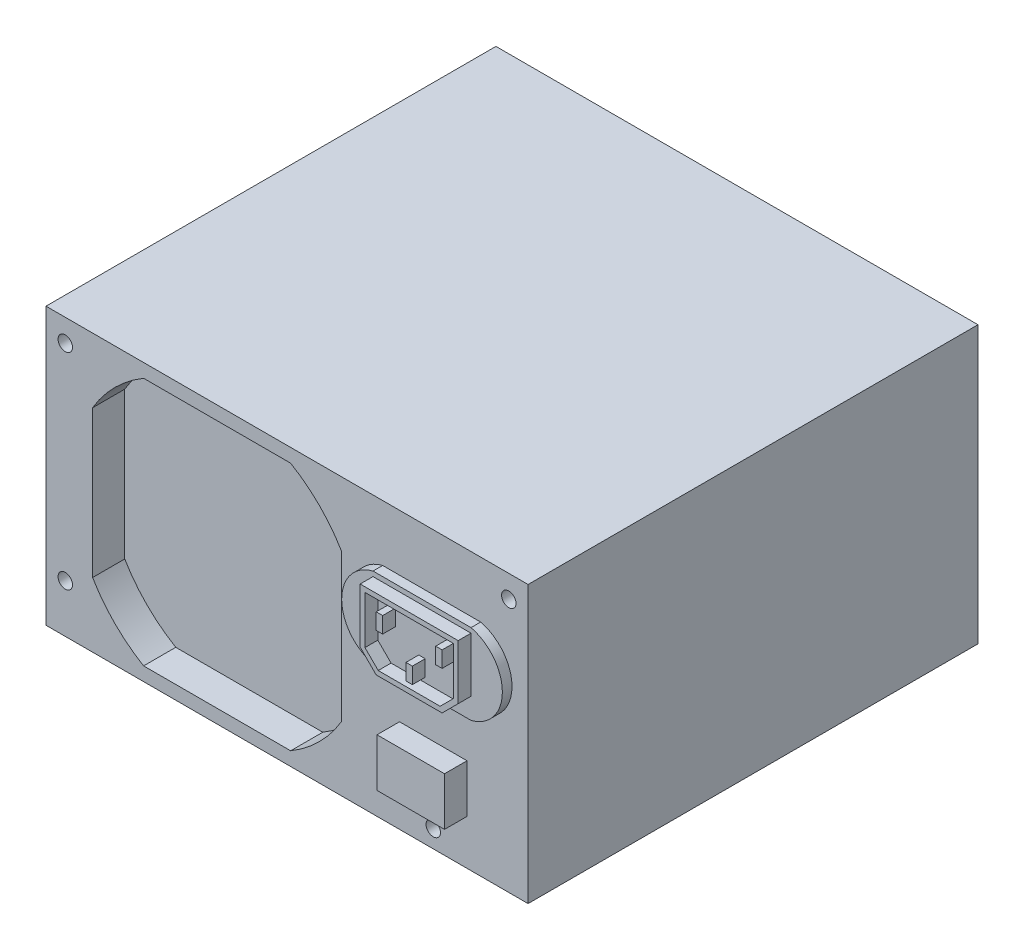
from build123d import *

# Parameters (mm, degrees)
SKETCH_1_W          = 150
SKETCH_1_H          = 86
EXTRUDE_1_DEPTH     = 140
SKETCH_4_R          = 2.25
CUT_EXTRUDE_1_DEPTH = 10
CUT_EXTRUDE_2_DEPTH = 10
EXTRUDE_2_DEPTH     = 3
SKETCH_7_W          = 2
SKETCH_7_H          = 5
EXTRUDE_3_DEPTH     = 4
SKETCH_8_W          = 21
SKETCH_8_H          = 15
EXTRUDE_4_DEPTH     = 7


with BuildPart() as part:
    # Эскиз1 → Бобышка-Вытянуть1 (new body)
    with BuildSketch(Plane.XY):
        with Locations((75, 43)):
            Rectangle(SKETCH_1_W, SKETCH_1_H)
    extrude(amount=EXTRUDE_1_DEPTH)

    # Эскиз4 → Вырез-Вытянуть1 (cut)
    with BuildSketch(Plane.XY.offset(140)):
        with Locations((6, 79)):
            Circle(SKETCH_4_R)
        with Locations((144, 79)):
            Circle(SKETCH_4_R)
        with Locations((6, 15)):
            Circle(SKETCH_4_R)
        with Locations((120.5, 5.5)):
            Circle(SKETCH_4_R)
    extrude(amount=-CUT_EXTRUDE_1_DEPTH, mode=Mode.SUBTRACT)

    # Эскиз5 → Вырез-Вытянуть2 (cut)
    with BuildSketch(Plane.XY.offset(140)):
        with BuildLine():
            Line((76.128756522, 81.75), (30.371243478, 81.75))
            ThreePointArc((30.371243478, 81.75), (21.430194847, 74.819805153), (14.5, 65.878756522))
            Line((14.5, 65.878756522), (14.5, 20.121243478))
            ThreePointArc((14.5, 20.121243478), (21.430194847, 11.180194847), (30.371243478, 4.25))
            Line((30.371243478, 4.25), (76.128756522, 4.25))
            ThreePointArc((76.128756522, 4.25), (85.069805153, 11.180194847), (92, 20.121243478))
            Line((92, 20.121243478), (92, 65.878756522))
            ThreePointArc((92, 65.878756522), (85.069805153, 74.819805153), (76.128756522, 81.75))
        make_face()
    extrude(amount=-CUT_EXTRUDE_2_DEPTH, mode=Mode.SUBTRACT)

    # Эскиз6 → Бобышка-Вытянуть2 (add)
    with BuildSketch(Plane.XY.offset(140)):
        with BuildLine():
            Line((104.75, 68.5), (135.25, 68.5))
            ThreePointArc((135.25, 68.5), (145, 56), (135.25, 43.5))
            Line((135.25, 43.5), (104.75, 43.5))
            ThreePointArc((104.75, 43.5), (95, 56), (104.75, 68.5))
        make_face()
    extrude(amount=EXTRUDE_2_DEPTH)

    # Эскиз7 → Бобышка-Вытянуть3 (add)
    with BuildSketch(Plane.XY.offset(143)):
        Polygon((109.75, 45), (130.25, 45), (135.25, 50), (135.25, 67), (104.75, 67), (104.75, 50), align=None)
        Polygon((110.371320344, 46.5), (106.25, 50.621320344), (106.25, 65.5), (133.75, 65.5), (133.75, 50.621320344), (129.628679656, 46.5), align=None, mode=Mode.SUBTRACT)
        with Locations((110.75, 59.5)):
            Rectangle(SKETCH_7_W, SKETCH_7_H)
        with Locations((129.25, 59.5)):
            Rectangle(SKETCH_7_W, SKETCH_7_H)
        with Locations((120, 50.5)):
            Rectangle(SKETCH_7_W, SKETCH_7_H)
    extrude(amount=EXTRUDE_3_DEPTH)

    # Эскиз8 → Бобышка-Вытянуть4 (add)
    with BuildSketch(Plane.XY.offset(140)):
        with Locations((120.5, 21.5)):
            Rectangle(SKETCH_8_W, SKETCH_8_H)
    extrude(amount=EXTRUDE_4_DEPTH)


solid = part.part
